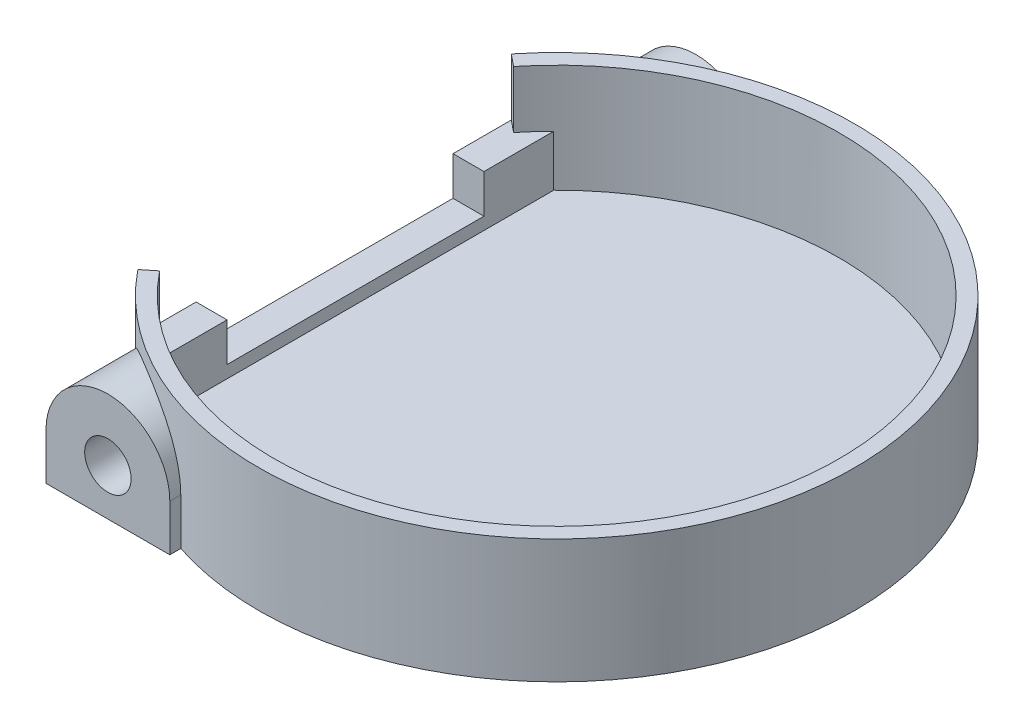
from build123d import *

# Parameters (mm, degrees)
BOSS_EXTRUDE1_DEPTH      = 7
BOSS_EXTRUDE2_DEPTH      = 1
SKETCH3_W                = 6.66403437
SKETCH3_H                = 33.73555596
CUT_EXTRUDE1_DEPTH       = 29.374724668
BOSS_EXTRUDE3_DEPTH      = 3.3
CUT_EXTRUDE2_DEPTH       = 3.7
SKETCH6_W                = 4
SKETCH6_H                = 16.6
CUT_EXTRUDE3_DEPTH       = 2.5
BOSS_EXTRUDE4_REACH      = 45.389
BOSS_EXTRUDE4_END_RADIUS = 19.25
SKETCH7_R                = 1.5


with BuildPart() as part:
    # Sketch1 → Boss-Extrude1 (new body)
    with BuildSketch(Plane(origin=(0, 0, 0), x_dir=(1, 0, 0), z_dir=(0, 1, 0))):
        with BuildLine():
            Line((-16, -10.703387314), (-16, 10.703387314))
            ThreePointArc((-16, 10.703387314), (19.25, 0), (-16, -10.703387314))
        make_face()
        with BuildLine():
            Line((-15, -10.395311443), (-15, 10.395311443))
            ThreePointArc((-15, 10.395311443), (18.25, 0), (-15, -10.395311443))
        make_face(mode=Mode.SUBTRACT)
    extrude(amount=BOSS_EXTRUDE1_DEPTH)

    # Sketch2 → Boss-Extrude2 (add)
    with BuildSketch(Plane.XZ):
        with BuildLine():
            Line((-16, 10.703387314), (-16, -10.703387314))
            ThreePointArc((-16, -10.703387314), (19.25, 0), (-16, 10.703387314))
        make_face()
    extrude(amount=BOSS_EXTRUDE2_DEPTH)

    # Sketch3 → Cut-Extrude1 (cut, through all)
    with BuildSketch(Plane(origin=(0, 7, 0), x_dir=(1, 0, 0), z_dir=(0, 1, 0))):
        with Locations((-18.332017185, -0.479198238)):
            Rectangle(SKETCH3_W, SKETCH3_H)
    extrude(amount=-CUT_EXTRUDE1_DEPTH, mode=Mode.SUBTRACT)

    # Sketch4 → Boss-Extrude3 (add)
    with BuildSketch(Plane(origin=(0, 0, 0), x_dir=(1, 0, 0), z_dir=(0, 1, 0))):
        Polygon((-15, 12.064928512), (-15, -12.064928512), (-13, -12.808688457), (-13, 12.808688457), align=None)
    extrude(amount=BOSS_EXTRUDE3_DEPTH)

    # Sketch5 → Cut-Extrude2 (cut)
    with BuildSketch(Plane(origin=(0, 7, 0), x_dir=(1, 0, 0), z_dir=(0, 1, 0))):
        Polygon((0, 0), (-15, -12.064928512), (-15, 12.064928512), align=None)
    extrude(amount=-CUT_EXTRUDE2_DEPTH, mode=Mode.SUBTRACT)

    # Sketch6 → Cut-Extrude3 (cut)
    with BuildSketch(Plane(origin=(0, 3.3, 0), x_dir=(1, 0, 0), z_dir=(0, 1, 0))):
        with Locations((-15, 0)):
            Rectangle(SKETCH6_W, SKETCH6_H)
    extrude(amount=-CUT_EXTRUDE3_DEPTH, mode=Mode.SUBTRACT)

    # Boss-Extrude4: up to this cylinder (the profile starts outside it)
    boss_extrude4_end = Plane(origin=(0, 0.5, 0), z_dir=(0, -1, 0)) * Cylinder(BOSS_EXTRUDE4_END_RADIUS, 130.278, mode=Mode.PRIVATE)
    # Sketch7 → Boss-Extrude4 (add, up to the surface)
    with BuildSketch(Plane.XY.offset(19), mode=Mode.PRIVATE) as boss_extrude4_sk1:
        with BuildLine():
            Line((-14, 2), (-14, -1))
            Line((-14, -1), (-6, -1))
            Line((-6, -1), (-6, 2))
            ThreePointArc((-6, 2), (-10, 6), (-14, 2))
        make_face()
        with Locations((-10, 2)):
            Circle(SKETCH7_R, mode=Mode.SUBTRACT)
    boss_extrude4_tool1 = extrude(boss_extrude4_sk1.sketch, amount=-BOSS_EXTRUDE4_REACH, mode=Mode.PRIVATE) - boss_extrude4_end
    boss_extrude4 = boss_extrude4_tool1.solids().sort_by_distance((-13.893699, 0.5, 19))[0]
    add(boss_extrude4)

    # Mirror1: Boss-Extrude4 across plane
    add(boss_extrude4.mirror(Plane.XY))


solid = part.part
